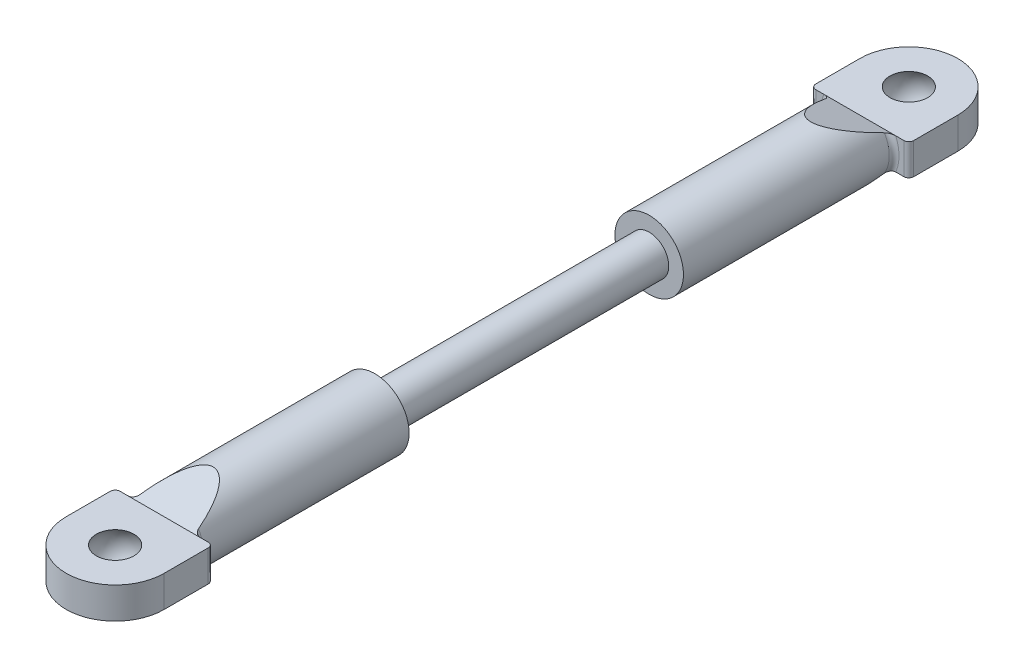
from build123d import *

# Parameters (mm, degrees)
SKETCH1_R                  = 2
SCREW_SECTION_DEPTH        = 14
SKETCH2_R                  = 3.5
BAR_SECTION_DEPTH          = 21.5
MOUNT_SECTION_DEPTH        = 1.6
BAR_TAPER_DEPTH            = 6
MOUNT_FILLET_R             = 0.5
MOUNT_FILLET_OF_MIRROR_2_R = 0.5


with BuildPart() as part:
    # Sketch1 → Screw Section (new body)
    with BuildSketch(Plane.XY):
        Circle(SKETCH1_R)
    screw_section = extrude(amount=SCREW_SECTION_DEPTH)

    # Sketch2 → Bar Section (add)
    with BuildSketch(Plane.XY.offset(14)):
        Circle(SKETCH2_R)
    bar_section = extrude(amount=BAR_SECTION_DEPTH)

    # Sketch3 → Mount Section (add, symmetric)
    with BuildSketch(Plane(origin=(0, 0, 0), x_dir=(1, 0, 0), z_dir=(0, 1, 0))):
        with BuildLine():
            Line((5, -35.5), (-5, -35.5))
            Line((-5, -35.5), (-5, -40.5))
            ThreePointArc((-5, -40.5), (0, -45.5), (5, -40.5))
            Line((5, -40.5), (5, -35.5))
        make_face()
    mount_section = extrude(amount=MOUNT_SECTION_DEPTH, both=True)

    # Sketch4 → Bar Taper (cut, symmetric)
    with BuildSketch(Plane(origin=(0, 0, 0), x_dir=(0, 0, -1), z_dir=(1, 0, 0))):
        Polygon((-30.5, -3.5), (-35.5, -1.6), (-35.5, -3.5), align=None)
        Polygon((-30.5, 3.5), (-35.5, 1.6), (-35.5, 3.5), align=None)
    bar_taper = extrude(amount=BAR_TAPER_DEPTH, both=True, mode=Mode.SUBTRACT)

    # Mount Fillet
    mount_fillet_edges = [part.edges().sort_by_distance(p)[0] for p in [
        (-5, 0, 35.5),
        (3.401842713, -0.823083322, 35.5),
        (-3.5, 0, 35.5),
        (5, 0, 35.5),
    ]]
    fillet(mount_fillet_edges, radius=MOUNT_FILLET_R)

    # Sketch6 → Ball Hole (revolve, cut)
    with BuildSketch(Plane(origin=(0, 0, 0), x_dir=(0, 0, -1), z_dir=(1, 0, 0))):
        with BuildLine():
            Line((-42.420937271, -1.6), (-40.5, -1.6))
            Line((-40.5, -1.6), (-40.5, 1.6))
            Line((-40.5, 1.6), (-42.420937271, 1.6))
            ThreePointArc((-42.420937271, 1.6), (-43, 0), (-42.420937271, -1.6))
        make_face()
    ball_hole = revolve(axis=Axis((0, -1.6, 40.5), (0, 1, 0)), mode=Mode.SUBTRACT)

    # Mirror 2: Screw Section, Bar Section, Mount Section, Bar Taper, Ball Hole across Front Plane
    add(screw_section.mirror(Plane.XY))
    add(bar_section.mirror(Plane.XY))
    add(mount_section.mirror(Plane.XY))
    add(bar_taper.mirror(Plane.XY), mode=Mode.SUBTRACT)
    add(ball_hole.mirror(Plane.XY), mode=Mode.SUBTRACT)

    # Mount Fillet of Mirror 2
    mount_fillet_of_mirror_2_edges = [part.edges().sort_by_distance(p)[0] for p in [
        (-5, 0, -35.5),
        (3.401842713, -0.823083322, -35.5),
        (-3.5, 0, -35.5),
        (5, 0, -35.5),
    ]]
    fillet(mount_fillet_of_mirror_2_edges, radius=MOUNT_FILLET_OF_MIRROR_2_R)


solid = part.part
